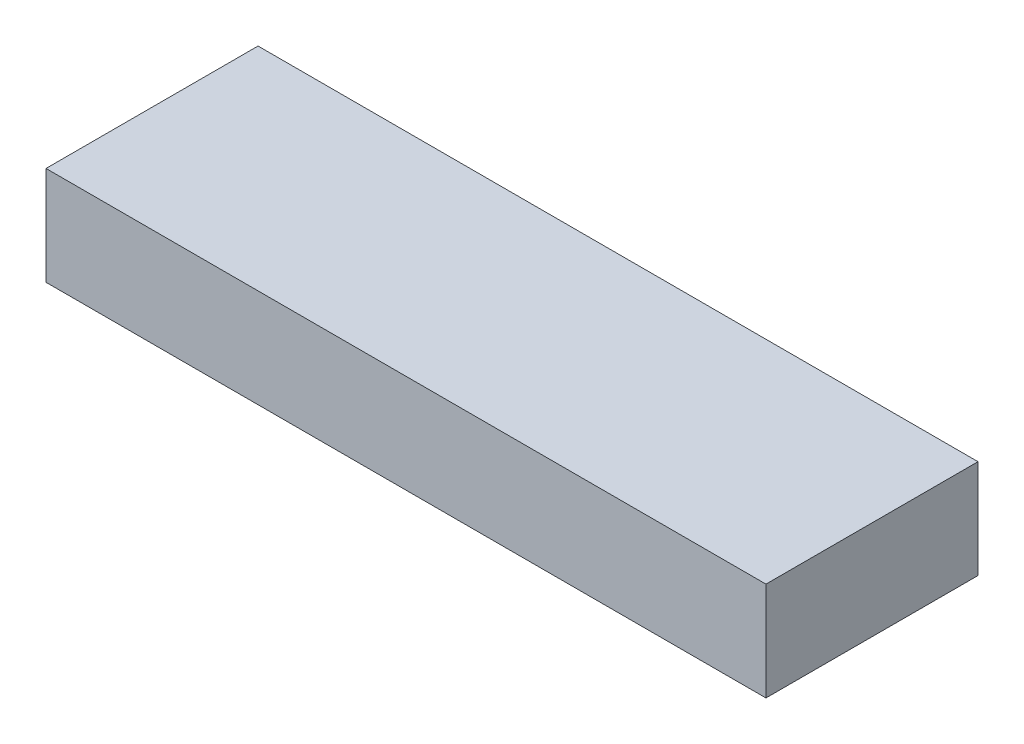
from build123d import *

# Parameters (mm, degrees)
SKETCH1_W           = 146
SKETCH1_H           = 43
BOSS_EXTRUDE1_DEPTH = 20


with BuildPart() as part:
    # Sketch1 → Boss-Extrude1 (new body)
    with BuildSketch(Plane(origin=(0, 0, 0), x_dir=(1, 0, 0), z_dir=(0, 1, 0))):
        Rectangle(SKETCH1_W, SKETCH1_H)
    extrude(amount=BOSS_EXTRUDE1_DEPTH)


solid = part.part
